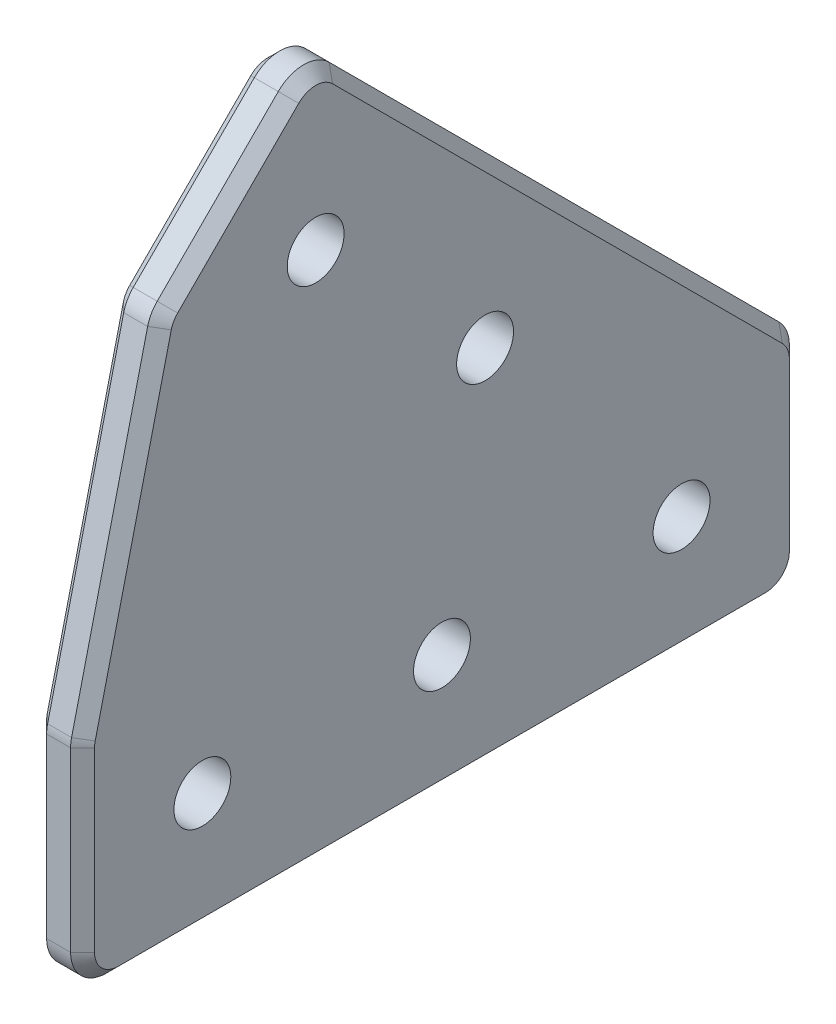
from build123d import *

# Parameters (mm, degrees)
BOSS_EXTRUDE1_DEPTH      = 4
SKETCH2_R                = 2.375
CUT_EXTRUDE1_DEPTH       = 5
LPATTERN1_COUNT          = 3
LPATTERN1_PITCH          = 20
SKETCH2_4_R              = 2.375
CUT_EXTRUDE2_DEPTH       = 5
LPATTERN2_COUNT          = 2
LPATTERN2_PITCH          = 20
FILLET1_R                = 3
CHANFRO1_SIZE            = 1
RESSALTO_EXTRUS_O1_START = -4
ESBO_O1_W                = 10
ESBO_O1_H                = 6
RESSALTO_EXTRUS_O1_DEPTH = 2


with BuildPart() as part:
    # Sketch1 → Boss-Extrude1 (new body)
    with BuildSketch(Plane(origin=(0, 0, 0), x_dir=(0, 0, -1), z_dir=(1, 0, 0))):
        Polygon((-78.140120378, 0), (-18.140120378, 0), (-18.140120378, 18.140120378), (-58.68306962, 58.68306962), (-71.510071751, 45.856067489), (-78.140120378, 18.140120378), align=None)
    extrude(amount=BOSS_EXTRUDE1_DEPTH)

    # Sketch2 → Cut-Extrude1 (cut, through all)
    with BuildSketch(Plane(origin=(4, 0, 0), x_dir=(0, 0, -1), z_dir=(1, 0, 0))):
        with Locations((-28.140120378, 10)):
            Circle(SKETCH2_R)
    cut_extrude1 = extrude(amount=-CUT_EXTRUDE1_DEPTH, mode=Mode.SUBTRACT)

    # LPattern1: Cut-Extrude1 ×3
    with Locations(*[(0, 0, i * LPATTERN1_PITCH) for i in range(1, LPATTERN1_COUNT)]):
        add(cut_extrude1, mode=Mode.SUBTRACT)

    # Sketch2_4 → Cut-Extrude2 (cut, through all)
    with BuildSketch(Plane(origin=(4, 0, 0), x_dir=(0, 0, -1), z_dir=(1, 0, 0))):
        with Locations((-58.68306962, 44.540933996)):
            Circle(SKETCH2_4_R)
    cut_extrude2 = extrude(amount=-CUT_EXTRUDE2_DEPTH, mode=Mode.SUBTRACT)

    # LPattern2: Cut-Extrude2 ×2
    with Locations(*[Vector(0, -0.707106781, -0.707106781) * (i * LPATTERN2_PITCH) for i in range(1, LPATTERN2_COUNT)]):
        add(cut_extrude2, mode=Mode.SUBTRACT)

    # Fillet1
    fillet1_edges = [part.edges().sort_by_distance(p)[0] for p in [
        (2, 18.140120378, 78.140120378),
        (2, 45.856067489, 71.510071751),
        (2, 58.68306962, 58.68306962),
        (2, 18.140120378, 18.140120378),
        (2, 0, 18.140120378),
        (2, 0, 78.140120378),
    ]]
    fillet(fillet1_edges, radius=FILLET1_R)

    # Chanfro1
    chanfro1_edges = [part.edges().sort_by_distance(p)[0] for p in [
        (0, 0, 48.140120378),
        (4, 0, 48.140120378),
        (0, 10.393145239, 78.140120378),
        (0, 31.75807492, 74.882512025),
        (0, 51.508513622, 65.857625619),
        (0, 37.790274655, 37.790274655),
        (0, 9.948739845, 18.140120378),
        (0, 57.440428933, 58.68306962),
        (0, 18.045529988, 18.36848178),
        (0, 0.878679656, 19.018800034),
        (0, 45.798751214, 71.407627967),
        (0, 18.137684762, 78.119469645),
        (0, 0.878679656, 77.261440721),
        (4, 10.393145239, 78.140120378),
        (4, 9.948739845, 18.140120378),
        (4, 37.790274655, 37.790274655),
        (4, 51.508513622, 65.857625619),
        (4, 31.75807492, 74.882512025),
        (4, 57.440428933, 58.68306962),
        (4, 18.045529988, 18.36848178),
        (4, 0.878679656, 19.018800034),
        (4, 45.798751214, 71.407627967),
        (4, 18.137684762, 78.119469645),
        (4, 0.878679656, 77.261440721),
    ]]
    chamfer(chanfro1_edges, length=CHANFRO1_SIZE)

    # Esbo_o1 → Ressalto-extrus_o1 (add)
    with BuildSketch(Plane(origin=(4, 0, 0), x_dir=(0, 0, -1), z_dir=(1, 0, 0)).offset(RESSALTO_EXTRUS_O1_START)):
        Polygon((-57.21666665, 39.183379746), (-50.59244791, 31.692069708), (-46.097661887, 35.666600952), (-52.721880627, 43.15791099), align=None)
        with Locations((-58.140120378, 10)):
            Rectangle(ESBO_O1_W, ESBO_O1_H)
        with Locations((-38.140120378, 10)):
            Rectangle(ESBO_O1_W, ESBO_O1_H)
    extrude(amount=-RESSALTO_EXTRUS_O1_DEPTH)


solid = part.part
